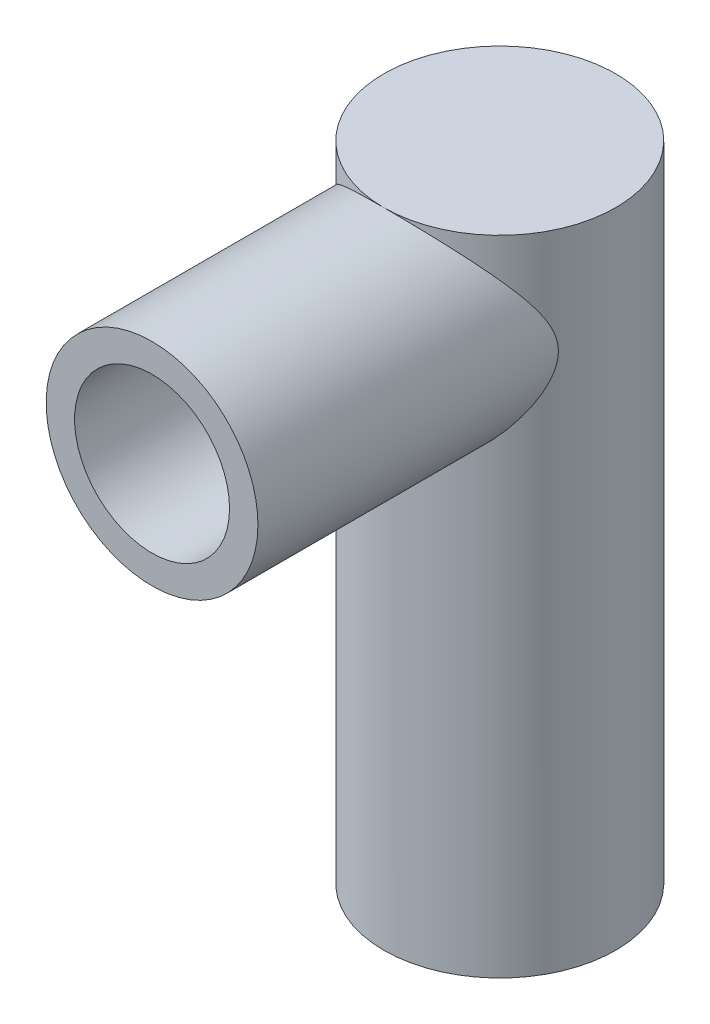
from build123d import *
from build123d.topology import SkipClean

# Parameters (mm, degrees)
SKETCH1_R           = 15.3
BOSS_EXTRUDE1_DEPTH = 84.864
SKETCH2_R           = 13.97
BOSS_EXTRUDE2_DEPTH = 57.15
BOSS_EXTRUDE3_DEPTH = 2.54
SKETCH4_R           = 10.2235
CUT_EXTRUDE1_DEPTH  = 5.08
SKETCH5_R           = 14.2621
SKETCH5_R_2         = 10.2235
BOSS_EXTRUDE4_DEPTH = 19.05
SKETCH6_R           = 10.75
CUT_EXTRUDE2_DEPTH  = 6.2
SKETCH8_R           = 14.2621
CUT_EXTRUDE5_DEPTH  = 10.16
SKETCH10_R          = 13.97
BOSS_EXTRUDE5_DEPTH = 24.13
SKETCH11_R          = 10.2235
CUT_EXTRUDE7_DEPTH  = 41.91
SKETCH13_R          = 14.2621
SKETCH13_R_2        = 10.2235
CUT_EXTRUDE9_DEPTH  = 41.91
SKETCH16_R          = 13.97
SKETCH16_R_2        = 10.2235
CUT_EXTRUDE10_DEPTH = 27.78125
SKETCH17_R          = 10.2235
CUT_EXTRUDE11_DEPTH = 27.686
SKETCH18_R          = 6.35
CUT_EXTRUDE12_DEPTH = 111.506


with BuildPart() as part:
    # Sketch1 → Boss-Extrude1 (new body)
    with BuildSketch(Plane(origin=(0, 0, 0), x_dir=(1, 0, 0), z_dir=(0, 1, 0))):
        with Locations(Location((0, 0, 0), (0, 0, 270))):
            Circle(SKETCH1_R)
    extrude(amount=BOSS_EXTRUDE1_DEPTH)

    # Sketch2 → Boss-Extrude2 (add)
    with BuildSketch(Plane.XY):
        with Locations(Location((0, 70.894, 0), (0, 0, 269.999999993))):
            Circle(SKETCH2_R)
    extrude(amount=BOSS_EXTRUDE2_DEPTH)

    # Sketch3 → Boss-Extrude3 (add, symmetric)
    with BuildSketch(Plane.XY.offset(57.15)):
        with BuildLine():
            Line((16.764, 70.894), (16.764, 40.838899717))
            ThreePointArc((16.764, 40.838899717), (0, 24.074899717), (-16.764, 40.838899717))
            Line((-16.764, 40.838899717), (-16.764, 70.894))
            ThreePointArc((-16.764, 70.894), (0, 87.658), (16.764, 70.894))
        make_face()
    extrude(amount=BOSS_EXTRUDE3_DEPTH, both=True)

    # Sketch4 → Cut-Extrude1 (cut)
    with BuildSketch(Plane.XY.offset(59.69)):
        with Locations((0, 40.838899717)):
            Circle(SKETCH4_R)
    extrude(amount=-CUT_EXTRUDE1_DEPTH, mode=Mode.SUBTRACT)

    # Sketch5 → Boss-Extrude4 (add, symmetric)
    with SkipClean():  # the faces are left unmerged after this step: merging them gives an invalid solid
        with BuildSketch(Plane(origin=(0, 0, 54.61), x_dir=(-1, 0, 0), z_dir=(0, 0, -1))):
            with Locations(Location((0, 40.838899717, 0), (0, 0, 180))):
                Circle(SKETCH5_R)
            with Locations((0, 40.838899717)):
                Circle(SKETCH5_R_2, mode=Mode.SUBTRACT)
        extrude(amount=BOSS_EXTRUDE4_DEPTH, both=True)

    # Sketch6 → Cut-Extrude2 (cut)
    with SkipClean():  # the faces are left unmerged after this step: merging them gives an invalid solid
        with BuildSketch(Plane.XZ):
            with Locations(Location((0, 0, 0), (0, 0, 270))):
                Circle(SKETCH6_R)
        extrude(amount=-CUT_EXTRUDE2_DEPTH, mode=Mode.SUBTRACT)

    # Sketch8 → Cut-Extrude5 (cut)
    with SkipClean():  # the faces are left unmerged after this step: merging them gives an invalid solid
        with BuildSketch(Plane.XY.offset(59.69)):
            with BuildLine():
                Line((-16.764, 70.894), (-16.764, 40.838899717))
                ThreePointArc((-16.764, 40.838899717), (0, 24.074899717), (16.764, 40.838899717))
                Line((16.764, 40.838899717), (16.764, 70.894))
                ThreePointArc((16.764, 70.894), (0, 87.658), (-16.764, 70.894))
            make_face()
            with Locations((0, 40.838899717)):
                Circle(SKETCH8_R, mode=Mode.SUBTRACT)
        extrude(amount=-CUT_EXTRUDE5_DEPTH, mode=Mode.SUBTRACT)


with BuildPart() as cut_extrude5_piece_1:
    # of the separate pieces the step leaves, piece 1, a body of its own (cut_extrude5_pieces)
    add(part.part.solids().sort_by_distance((0, 0, 15.3))[0])

    # Sketch10 → Boss-Extrude5 (add)
    with BuildSketch(Plane.XY.offset(49.53)):
        with Locations(Location((0, 70.894, 0), (0, 0, 90))):
            Circle(SKETCH10_R)
    extrude(amount=BOSS_EXTRUDE5_DEPTH)

    # Sketch11 → Cut-Extrude7 (cut)
    with BuildSketch(Plane.XY.offset(73.66)):
        with Locations((0, 70.894)):
            Circle(SKETCH11_R)
    extrude(amount=-CUT_EXTRUDE7_DEPTH, mode=Mode.SUBTRACT)

    # Sketch16 → Cut-Extrude10 (cut)
    with BuildSketch(Plane.XY.offset(73.66)):
        with Locations(Location((0, 70.894, 0), (0, 0, 90))):
            Circle(SKETCH16_R)
        with Locations((0, 70.894)):
            Circle(SKETCH16_R_2, mode=Mode.SUBTRACT)
    extrude(amount=-CUT_EXTRUDE10_DEPTH, mode=Mode.SUBTRACT)

    # Sketch17 → Cut-Extrude11 (cut)
    with BuildSketch(Plane.XY.offset(31.75)):
        with Locations((0, 70.894)):
            Circle(SKETCH17_R)
    extrude(amount=-CUT_EXTRUDE11_DEPTH, mode=Mode.SUBTRACT)

    # Sketch18 → Cut-Extrude12 (cut)
    with BuildSketch(Plane.XY.offset(4.064)):
        with Locations((0, 70.894)):
            Circle(SKETCH18_R)
    extrude(amount=-CUT_EXTRUDE12_DEPTH, mode=Mode.SUBTRACT)


with BuildPart() as cut_extrude5_piece_2:
    # of the separate pieces the step leaves, piece 2, a body of its own (cut_extrude5_pieces)
    add(part.part.solids().sort_by_distance((14.2621, 40.838899717, 54.61))[0])

    # Sketch13 → Cut-Extrude9 (cut)
    with BuildSketch(Plane.XY.offset(73.66)):
        with Locations((0, 40.838899717)):
            Circle(SKETCH13_R)
        with Locations((0, 40.838899717)):
            Circle(SKETCH13_R_2, mode=Mode.SUBTRACT)
    extrude(amount=-CUT_EXTRUDE9_DEPTH, mode=Mode.SUBTRACT)


solid = cut_extrude5_piece_1.part
